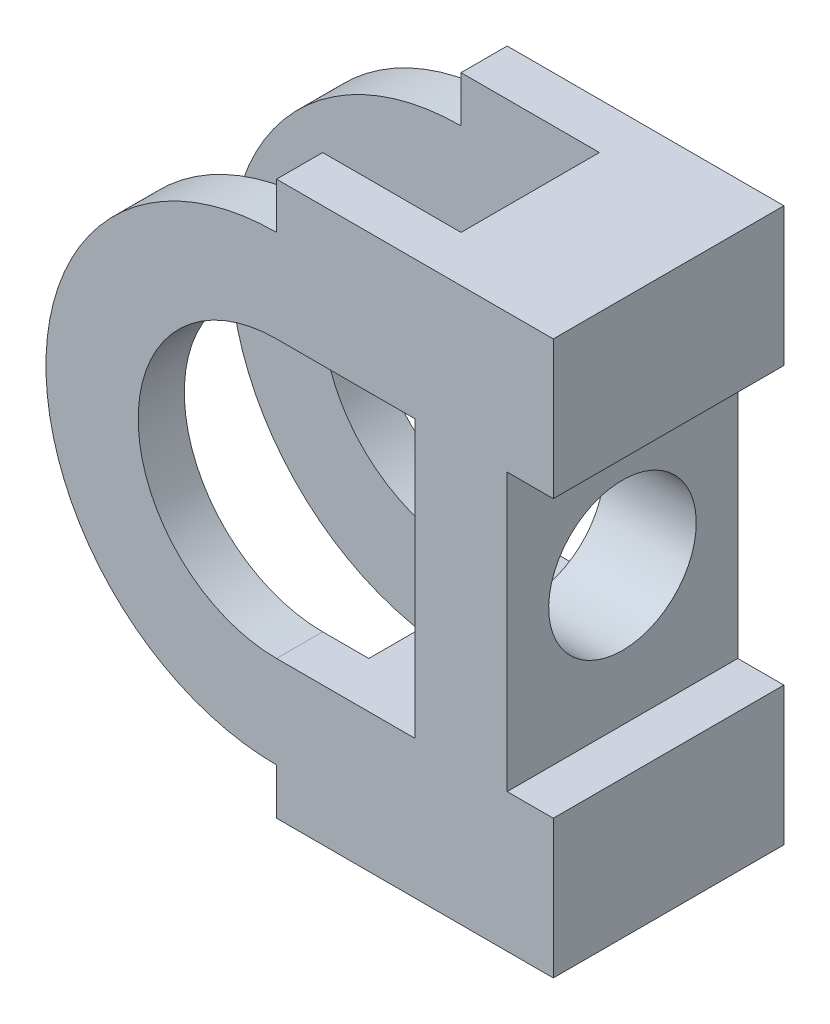
from build123d import *

# Parameters (mm, degrees)
BOSS_EXTRUDE1_DEPTH = 50
SKETCH2_W           = 10
SKETCH2_H           = 60
CUT_EXTRUDE1_DEPTH  = 50
CUT_EXTRUDE2_DEPTH  = 50
SKETCH4_W           = 60
SKETCH4_H           = 30
CUT_EXTRUDE3_DEPTH  = 177
SKETCH5_R           = 16
CUT_EXTRUDE5_DEPTH  = 177
SKETCH6_W           = 20
SKETCH6_H           = 30
CUT_EXTRUDE6_DEPTH  = 20
SKETCH7_W           = 20
SKETCH7_H           = 30
CUT_EXTRUDE7_DEPTH  = 20


with BuildPart() as part:
    # Sketch1 → Boss-Extrude1 (new body)
    with BuildSketch(Plane.XY):
        with BuildLine():
            Line((0, 120), (0, 110))
            ThreePointArc((0, 110), (-50, 60), (0, 10))
            Line((0, 10), (0, 0))
            Line((0, 0), (60, 0))
            Line((60, 0), (60, 120))
            Line((60, 120), (0, 120))
        make_face()
    extrude(amount=BOSS_EXTRUDE1_DEPTH)

    # Sketch2 → Cut-Extrude1 (cut)
    with BuildSketch(Plane.XY.offset(50)):
        with Locations((55, 60)):
            Rectangle(SKETCH2_W, SKETCH2_H)
    extrude(amount=-CUT_EXTRUDE1_DEPTH, mode=Mode.SUBTRACT)

    # Sketch3 → Cut-Extrude2 (cut)
    with BuildSketch(Plane.XY.offset(50)):
        with BuildLine():
            Line((30, 90), (30, 30))
            Line((30, 30), (0, 30))
            ThreePointArc((0, 30), (-30, 60), (0, 90))
            Line((0, 90), (30, 90))
        make_face()
    extrude(amount=-CUT_EXTRUDE2_DEPTH, mode=Mode.SUBTRACT)

    # Sketch4 → Cut-Extrude3 (cut)
    with BuildSketch(Plane(origin=(0, 120, 0), x_dir=(1, 0, 0), z_dir=(0, 1, 0))):
        with Locations((-20, -25)):
            Rectangle(SKETCH4_W, SKETCH4_H)
    extrude(amount=-CUT_EXTRUDE3_DEPTH, mode=Mode.SUBTRACT)

    # Sketch5 → Cut-Extrude5 (cut)
    with BuildSketch(Plane.ZY.offset(-30)):
        with Locations((25, 60)):
            Circle(SKETCH5_R)
    extrude(amount=-CUT_EXTRUDE5_DEPTH, mode=Mode.SUBTRACT)

    # Sketch6 → Cut-Extrude6 (cut)
    with BuildSketch(Plane(origin=(0, 120, 0), x_dir=(1, 0, 0), z_dir=(0, 1, 0))):
        with Locations((20, -25)):
            Rectangle(SKETCH6_W, SKETCH6_H)
    extrude(amount=-CUT_EXTRUDE6_DEPTH, mode=Mode.SUBTRACT)

    # Sketch7 → Cut-Extrude7 (cut)
    with BuildSketch(Plane.XZ):
        with Locations((20, 25)):
            Rectangle(SKETCH7_W, SKETCH7_H)
    extrude(amount=-CUT_EXTRUDE7_DEPTH, mode=Mode.SUBTRACT)


solid = part.part
